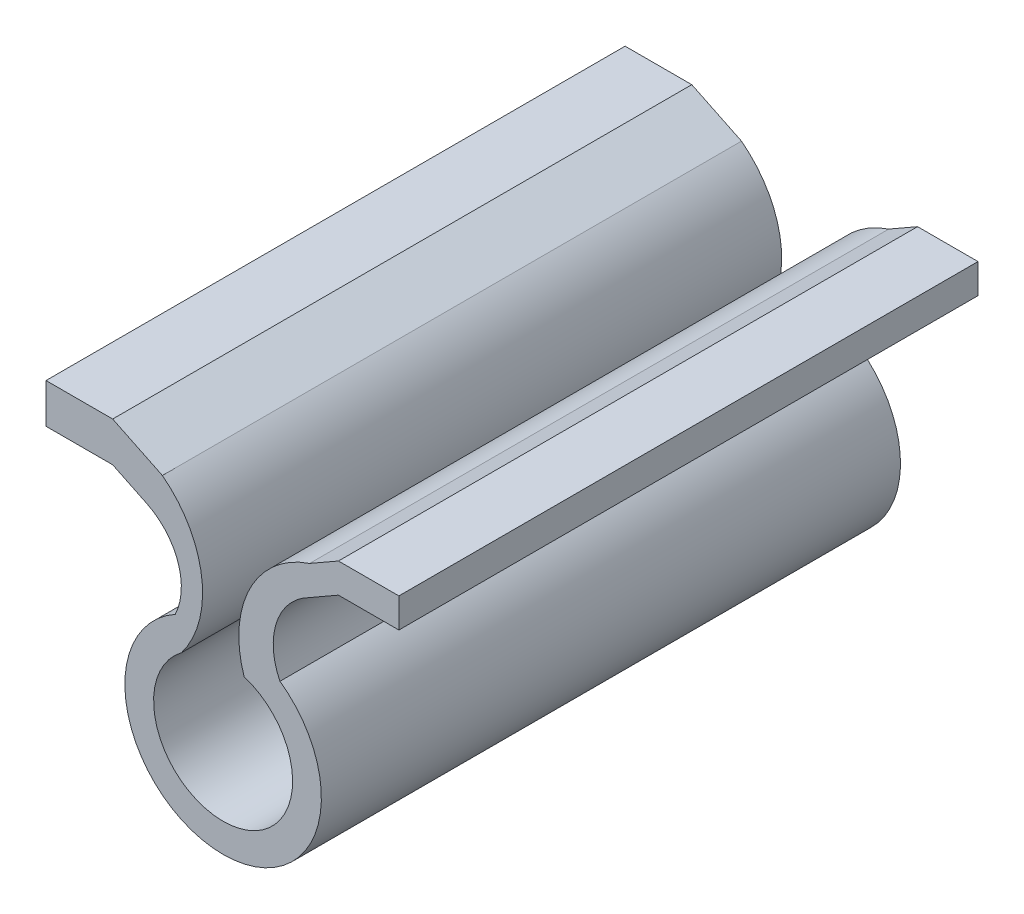
from build123d import *

# Parameters (mm, degrees)
BOSS_EXTRUDE1_DEPTH = 50


with BuildPart() as part:
    # Sketch1 → Boss-Extrude1 (new body)
    with BuildSketch(Plane.XY):
        with BuildLine():
            Line((-6.586608294, 14.460119027), (-9.534784216, 15.886812091))
            Line((-9.534784216, 15.886812091), (-15.291700897, 15.886812091))
            Line((-15.291700897, 15.886812091), (-15.291700897, 19.310099191))
            Line((-15.291700897, 19.310099191), (-9.534784216, 19.310099191))
            Line((-9.534784216, 19.310099191), (-5.244334477, 17.233847622))
            ThreePointArc((-5.244334477, 17.233847622), (-1.849307759, 11.35362893), (-3.606603855, 4.795040003))
            ThreePointArc((-3.606603855, 4.795040003), (1.009509443, -5.914464531), (1.811864615, 5.719890438))
            ThreePointArc((1.811864615, 5.719890438), (2.300023264, 12.537382377), (7.465898335, 17.012896867))
            Line((7.465898335, 17.012896867), (9.956628937, 18.439589931))
            Line((9.956628937, 18.439589931), (15.176123212, 18.439589931))
            Line((15.176123212, 18.439589931), (15.176123212, 15.886812091))
            Line((15.176123212, 15.886812091), (9.956628937, 15.886812091))
            Line((9.956628937, 15.886812091), (7.465898335, 14.460119027))
            ThreePointArc((7.465898335, 14.460119027), (4.624724664, 11.219877568), (4.906908203, 6.919667691))
            ThreePointArc((4.906908203, 6.919667691), (-0.457047842, -8.470575915), (-4.133856573, 7.407481279))
            ThreePointArc((-4.133856573, 7.407481279), (-3.899583331, 11.441781667), (-6.586608294, 14.460119027))
        make_face()
    extrude(amount=-BOSS_EXTRUDE1_DEPTH)


solid = part.part
